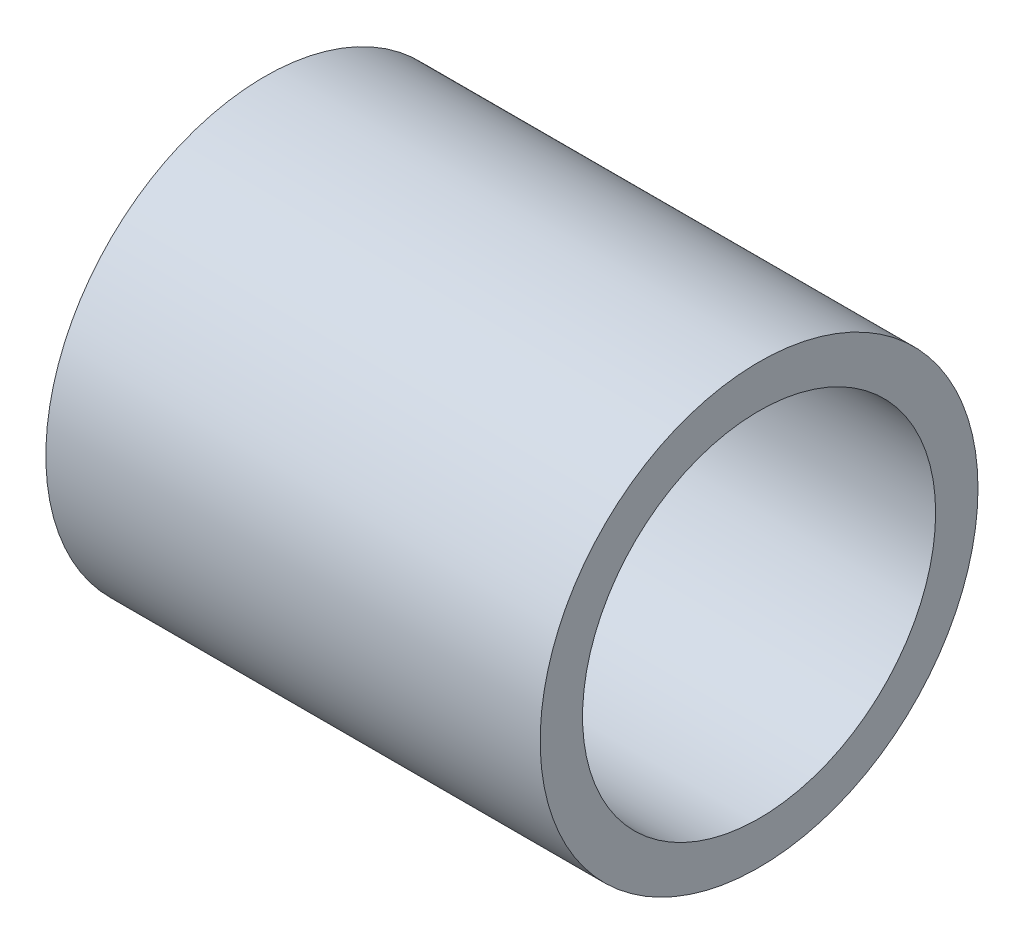
from build123d import *

# Parameters (mm, degrees)
SZKIC1_R                    = 15.5
SZKIC1_R_2                  = 12.5
DODANIE_WYCI_GNI_CIE1_DEPTH = 35


with BuildPart() as part:
    # Szkic1 → Dodanie-wyciągnięcie1 (new body)
    with BuildSketch(Plane(origin=(0, 0, 0), x_dir=(0, 0, -1), z_dir=(1, 0, 0))):
        Circle(SZKIC1_R)
        Circle(SZKIC1_R_2, mode=Mode.SUBTRACT)
    extrude(amount=DODANIE_WYCI_GNI_CIE1_DEPTH)


solid = part.part
